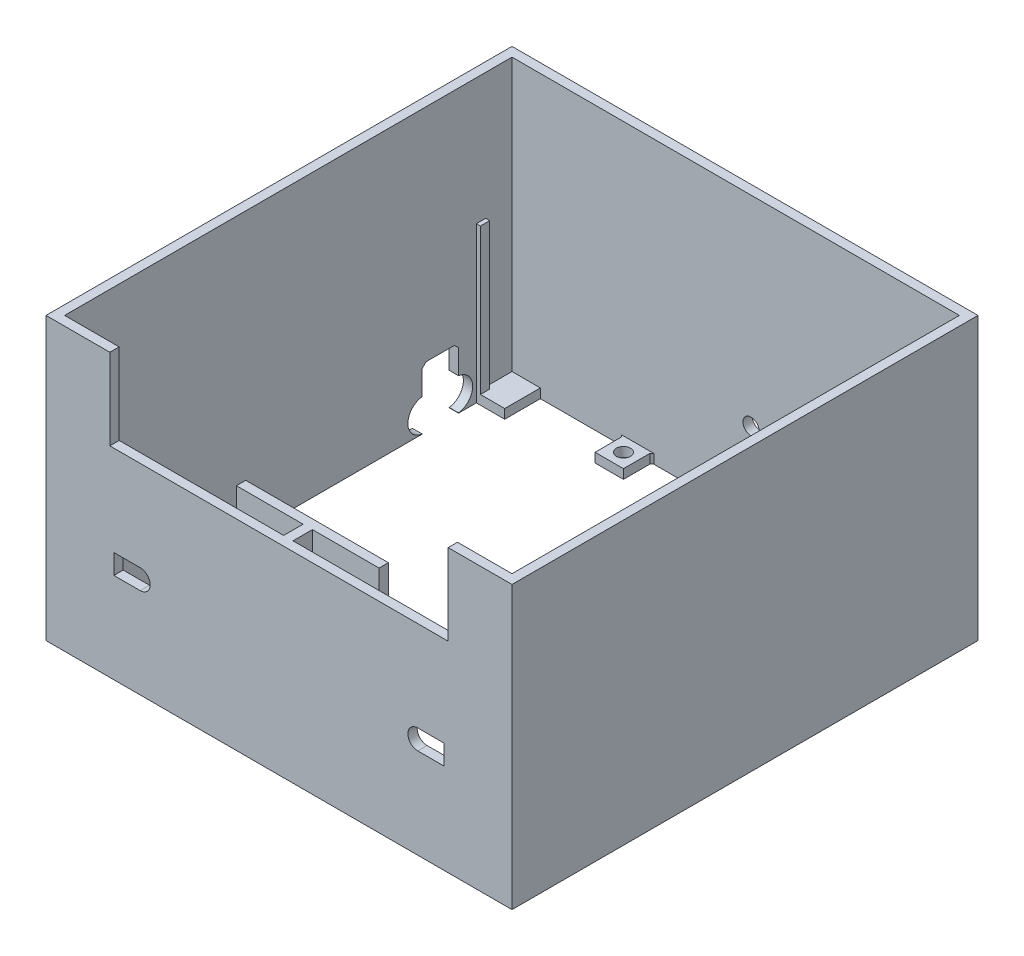
from build123d import *

# Parameters (mm, degrees)
SKETCH1_W            = 35.2
SKETCH1_H            = 49.5
BOSS_EXTRUDE1_DEPTH  = 2.3
SKETCH2_W            = 2.3
SKETCH2_H            = 49.5
BOSS_EXTRUDE2_DEPTH  = 4.8
SKETCH3_W            = 83.5
SKETCH3_H            = 49.5
BOSS_EXTRUDE3_DEPTH  = 2.3
CUT_EXTRUDE1_DEPTH   = 50.436676668
BOSS_EXTRUDE10_DEPTH = 69.5
SKETCH7_W            = 7
SKETCH7_H            = 7
SKETCH7_R            = 1.75
BOSS_EXTRUDE7_DEPTH  = 2.3
CHAMFER1_SIZE        = 0.5
SKETCH12_W           = 7
SKETCH12_H           = 2.3
BOSS_EXTRUDE11_DEPTH = 8.8
SKETCH13_W           = 2.3
SKETCH13_H           = 2.3
SKETCH13_W_2         = 1
BOSS_EXTRUDE12_DEPTH = 36
SKETCH14_R           = 1
SKETCH14_R_2         = 2
CUT_EXTRUDE3_DEPTH   = 135.201723163
CUT_EXTRUDE4_REACH   = 164.416
SKETCH18_R           = 4
SKETCH18_W           = 9
SKETCH18_H           = 15
CHAMFER2_SIZE        = 1


with BuildPart() as part:
    # Sketch1 → Boss-Extrude1 (new body)
    with BuildSketch(Plane.XY):
        Rectangle(SKETCH1_W, SKETCH1_H)
    extrude(amount=BOSS_EXTRUDE1_DEPTH)

    # Sketch2 → Boss-Extrude2 (add)
    with BuildSketch(Plane.XY.offset(2.3)):
        Rectangle(SKETCH2_W, SKETCH2_H)
    extrude(amount=BOSS_EXTRUDE2_DEPTH)

    # Sketch3 → Boss-Extrude3 (add)
    with BuildSketch(Plane.XY.offset(7.1)):
        Rectangle(SKETCH3_W, SKETCH3_H)
    extrude(amount=BOSS_EXTRUDE3_DEPTH)

    # Sketch4 → Cut-Extrude1 (cut, through all)
    with BuildSketch(Plane.XY.offset(9.4)):
        with BuildLine():
            Line((-34.25, 2.45), (-40.75, 2.45))
            Line((-40.75, 2.45), (-40.75, -2.45))
            Line((-40.75, -2.45), (-34.25, -2.45))
            ThreePointArc((-34.25, -2.45), (-36.7, 0), (-34.25, 2.45))
        make_face()
        with BuildLine():
            ThreePointArc((-31.8, 0), (-32.517588386, 1.732411614), (-34.25, 2.45))
            Line((-34.25, 2.45), (-34.25, -2.45))
            ThreePointArc((-34.25, -2.45), (-32.517588386, -1.732411614), (-31.8, 0))
        make_face()
        with BuildLine():
            Line((-34.25, -2.45), (-34.25, 2.45))
            ThreePointArc((-34.25, 2.45), (-36.7, 0), (-34.25, -2.45))
        make_face()
        with BuildLine():
            ThreePointArc((34.25, 2.45), (31.8, 0), (34.25, -2.45))
            Line((34.25, -2.45), (34.25, 2.45))
        make_face()
        with BuildLine():
            Line((34.25, 2.45), (34.25, -2.45))
            ThreePointArc((34.25, -2.45), (35.982411614, -1.732411614), (36.7, 0))
            ThreePointArc((36.7, 0), (35.982411614, 1.732411614), (34.25, 2.45))
        make_face()
        with BuildLine():
            Line((34.25, -2.45), (40.75, -2.45))
            Line((40.75, -2.45), (40.75, 2.45))
            Line((40.75, 2.45), (34.25, 2.45))
            ThreePointArc((34.25, 2.45), (35.982411614, 1.732411614), (36.7, 0))
            ThreePointArc((36.7, 0), (35.982411614, -1.732411614), (34.25, -2.45))
        make_face()
    extrude(amount=-CUT_EXTRUDE1_DEPTH, mode=Mode.SUBTRACT)

    # Sketch10 → Boss-Extrude10 (add)
    with BuildSketch(Plane.XZ.offset(24.75)):
        Polygon((-41.75, 7.1), (-41.75, 9.4), (-57.5, 9.4), (-57.5, -105.6), (57.5, -105.6), (57.5, 9.4), (41.75, 9.4), (41.75, 7.1), (55.2, 7.1), (55.2, -103.3), (-55.2, -103.3), (-55.2, 7.1), align=None)
    extrude(amount=-BOSS_EXTRUDE10_DEPTH)

    # Sketch7 → Boss-Extrude7 (add)
    with BuildSketch(Plane.XZ.offset(24.75)):
        with Locations((-24.2, 3.6)):
            Rectangle(SKETCH7_W, SKETCH7_H)
        with Locations(Location((-24.2, 3.6, 0), (0, 0, 270))):
            Circle(SKETCH7_R, mode=Mode.SUBTRACT)
        with Locations((24.2, 3.6)):
            Rectangle(SKETCH7_W, SKETCH7_H)
        with Locations(Location((24.2, 3.6, 0), (0, 0, 90))):
            Circle(SKETCH7_R, mode=Mode.SUBTRACT)
        with Locations((24.2, -99.8)):
            Rectangle(SKETCH7_W, SKETCH7_H)
        with Locations(Location((24.2, -99.8, 0), (0, 0, 270))):
            Circle(SKETCH7_R, mode=Mode.SUBTRACT)
        with Locations((-24.2, -99.8)):
            Rectangle(SKETCH7_W, SKETCH7_H)
        with Locations(Location((-24.2, -99.8, 0), (0, 0, 90))):
            Circle(SKETCH7_R, mode=Mode.SUBTRACT)
    extrude(amount=-BOSS_EXTRUDE7_DEPTH)

    # Chamfer1
    chamfer1_edges = [part.edges().sort_by_distance(p)[0] for p in [
        (-27.7, -23.6, 7.1),
        (-20.7, -23.6, 7.1),
        (27.7, -23.6, 7.1),
        (20.7, -23.6, 7.1),
        (27.7, -23.6, -103.3),
        (20.7, -23.6, -103.3),
        (-27.7, -23.6, -103.3),
        (-20.7, -23.6, -103.3),
    ]]
    chamfer(chamfer1_edges, length=CHAMFER1_SIZE)

    # Sketch12 → Boss-Extrude11 (add)
    with BuildSketch(Plane.XY.offset(-103.3)):
        with Locations((51.7, -23.6)):
            Rectangle(SKETCH12_W, SKETCH12_H)
        with Locations((-51.7, -23.6)):
            Rectangle(SKETCH12_W, SKETCH12_H)
    extrude(amount=BOSS_EXTRUDE11_DEPTH)

    # Sketch13 → Boss-Extrude12 (add)
    with BuildSketch(Plane(origin=(0, -22.45, 0), x_dir=(1, 0, 0), z_dir=(0, 1, 0))):
        with Locations((54.05, 95.65)):
            Rectangle(SKETCH13_W, SKETCH13_H)
        with Locations((-54.7, 95.65)):
            Rectangle(SKETCH13_W_2, SKETCH13_H)
    extrude(amount=BOSS_EXTRUDE12_DEPTH)

    # Sketch14 → Cut-Extrude3 (cut, through all)
    with BuildSketch(Plane.XY.offset(-103.3)):
        with Locations((46.7, -4.7)):
            Circle(SKETCH14_R)
        with Locations((38.2, -4.7)):
            Circle(SKETCH14_R)
        with Locations((29.7, -4.7)):
            Circle(SKETCH14_R)
        with Locations((21.2, -4.7)):
            Circle(SKETCH14_R)
        with Locations((3.8, -4.7)):
            Circle(SKETCH14_R_2)
    extrude(amount=-CUT_EXTRUDE3_DEPTH, mode=Mode.SUBTRACT)

    # Sketch18 → Cut-Extrude4 (cut, up to next)
    with BuildSketch(Plane.ZY.offset(57.5), mode=Mode.PRIVATE) as cut_extrude4_sk1:
        with Locations((-89.6, -20.71)):
            Circle(SKETCH18_R)
    cut_extrude4_tool1 = extrude(cut_extrude4_sk1.sketch, amount=-CUT_EXTRUDE4_REACH, mode=Mode.PRIVATE) & part.part
    # Sketch18 → Cut-Extrude4 (cut, up to next)
    with BuildSketch(Plane.ZY.offset(57.5), mode=Mode.PRIVATE) as cut_extrude4_sk2:
        with Locations((-81.6, -20.71)):
            Circle(SKETCH18_R)
    cut_extrude4_tool2 = extrude(cut_extrude4_sk2.sketch, amount=-CUT_EXTRUDE4_REACH, mode=Mode.PRIVATE) & part.part
    # Sketch18 → Cut-Extrude4 (cut, up to next)
    with BuildSketch(Plane.ZY.offset(57.5), mode=Mode.PRIVATE) as cut_extrude4_sk3:
        with Locations((-85.6, -17.25)):
            Rectangle(SKETCH18_W, SKETCH18_H)
    cut_extrude4_tool3 = extrude(cut_extrude4_sk3.sketch, amount=-CUT_EXTRUDE4_REACH, mode=Mode.PRIVATE) & part.part
    add(cut_extrude4_tool1.solids().sort_by_distance((-57.5, -20.71, -89.6))[0], mode=Mode.SUBTRACT)
    add(cut_extrude4_tool2.solids().sort_by_distance((-57.5, -20.71, -81.6))[0], mode=Mode.SUBTRACT)
    add(cut_extrude4_tool3.solids().sort_by_distance((-57.5, -17.25, -85.6))[0], mode=Mode.SUBTRACT)

    # Chamfer2
    chamfer2_edges = [part.edges().sort_by_distance(p)[0] for p in [
        (-56.35, -9.75, -81.1),
        (-56.35, -9.75, -90.1),
    ]]
    chamfer(chamfer2_edges, length=CHAMFER2_SIZE)


solid = part.part
